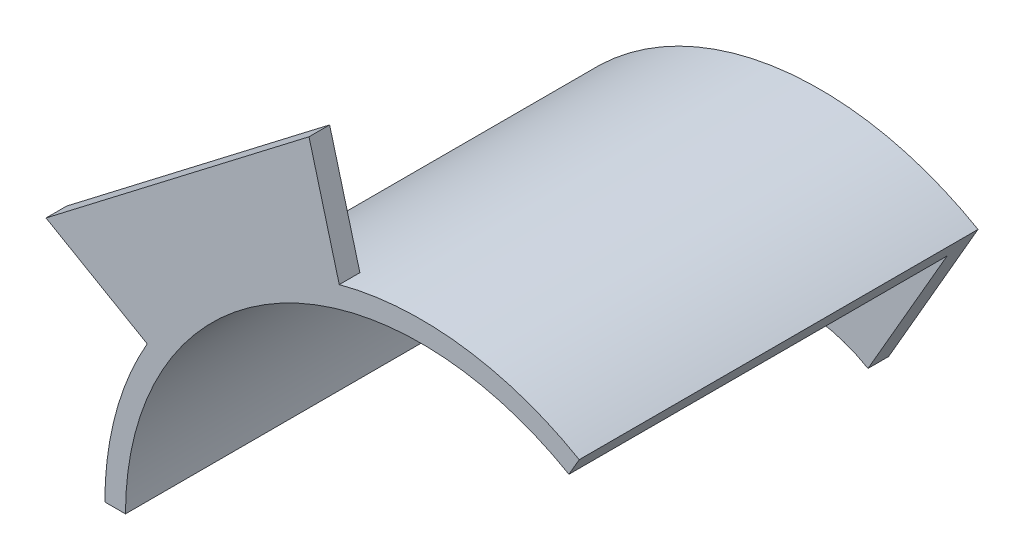
from build123d import *

# Parameters (mm, degrees)
SKETCH1_R           = 46
SKETCH1_R_2         = 43
BOSS_EXTRUDE1_DEPTH = 55
BOSS_EXTRUDE2_START = 3
BOSS_EXTRUDE2_DEPTH = 3
CUT_EXTRUDE1_DEPTH  = 58
BOSS_EXTRUDE3_START = -3
BOSS_EXTRUDE3_DEPTH = 3


with BuildPart() as part:
    # Sketch1 → Boss-Extrude1 (new body)
    with BuildSketch(Plane.XY):
        Circle(SKETCH1_R)
        Circle(SKETCH1_R_2, mode=Mode.SUBTRACT)
    extrude(amount=BOSS_EXTRUDE1_DEPTH)

    # Sketch2 → Boss-Extrude2 (add)
    with BuildSketch(Plane(origin=(0, 0, 0), x_dir=(-1, 0, 0), z_dir=(0, 0, -1)).offset(BOSS_EXTRUDE2_START)):
        with BuildLine():
            Line((-10, 17.320508076), (-23, 39.837168574))
            ThreePointArc((-23, 39.837168574), (23, 39.837168574), (46, 0))
            Line((46, 0), (20, 0))
            ThreePointArc((20, 0), (10, 17.320508076), (-10, 17.320508076))
        make_face()
    extrude(amount=-BOSS_EXTRUDE2_DEPTH)

    # Sketch3 → Cut-Extrude1 (cut)
    with BuildSketch(Plane(origin=(0, 0, -3), x_dir=(-1, 0, 0), z_dir=(0, 0, -1))):
        with BuildLine():
            Line((-23, 39.837168574), (-21.5, 37.239092363))
            ThreePointArc((-21.5, 37.239092363), (-21.5, -37.239092363), (43, 0))
            Line((43, 0), (46, 0))
            ThreePointArc((46, 0), (-23, -39.837168574), (-23, 39.837168574))
        make_face()
    extrude(amount=-CUT_EXTRUDE1_DEPTH, mode=Mode.SUBTRACT)

    # Sketch4 → Boss-Extrude3 (add)
    with BuildSketch(Plane.XY.offset(55).offset(BOSS_EXTRUDE3_START)):
        with BuildLine():
            Line((-37.239092363, 21.5), (-54.559600438, 31.5))
            Line((-54.559600438, 31.5), (-16.305599841, 60.853327056))
            Line((-16.305599841, 60.853327056), (-11.129218939, 41.53481053))
            ThreePointArc((-11.129218939, 41.53481053), (-26.176741447, 34.114193633), (-37.239092363, 21.5))
        make_face()
    extrude(amount=BOSS_EXTRUDE3_DEPTH)


solid = part.part
